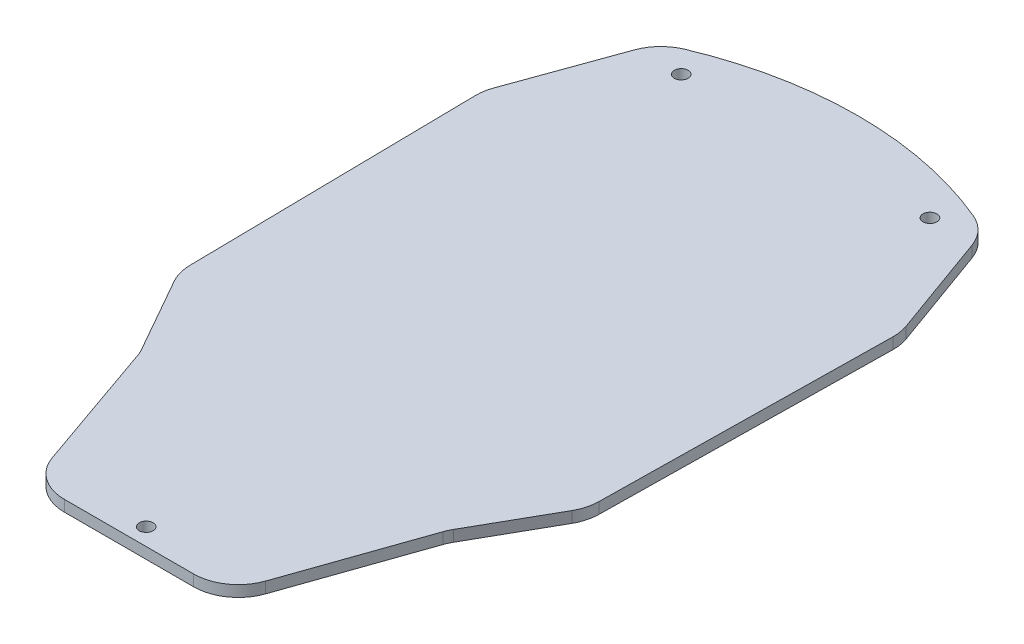
from build123d import *

# Parameters (mm, degrees)
BOSS_EXTRUDE1_DEPTH             = 3.175
F_5_32_0_15625_DIAMETER_HOLE1_D = 3.96875
FILLET1_R                       = 12.7


with BuildPart() as part:
    # Sketch1 → Boss-Extrude1 (new body)
    with BuildSketch(Plane(origin=(0, 0, 0), x_dir=(1, 0, 0), z_dir=(0, 1, 0))):
        with BuildLine():
            Line((-58.261140344, 73.958269638), (-59.57789635, 162.152192036))
            Line((-59.57789635, 162.152192036), (-46.350471986, 198.78134649))
            ThreePointArc((-46.350471986, 198.78134649), (0, 209.411849995), (46.350471986, 198.78134649))
            Line((46.350471986, 198.78134649), (59.57789635, 162.152192036))
            Line((59.57789635, 162.152192036), (58.261140344, 73.958269638))
            Line((58.261140344, 73.958269638), (43.887596105, 48.613026492))
            Line((43.887596105, 48.613026492), (27.448255842, 1.5875))
            Line((27.448255842, 1.5875), (-27.448255842, 1.5875))
            Line((-27.448255842, 1.5875), (-43.887596105, 48.613026492))
            Line((-43.887596105, 48.613026492), (-58.261140344, 73.958269638))
        make_face()
    extrude(amount=BOSS_EXTRUDE1_DEPTH)

    # 5/32 (0.15625) Diameter Hole1 (through all)
    with Locations(Plane(origin=(0, 3.175, 0), x_dir=(1, 0, 0), z_dir=(0, 1, 0))):
        with Locations((0, 6.48335), (-35.45205, 194.449583064), (35.45205, 194.449583064)):
            Hole(F_5_32_0_15625_DIAMETER_HOLE1_D / 2)

    # Fillet1
    fillet1_edges = [part.edges().sort_by_distance(p)[0] for p in [
        (-59.57789635, 1.5875, -162.152192036),
        (-58.261140344, 1.5875, -73.958269638),
        (-43.887596105, 1.5875, -48.613026492),
        (-27.448255842, 1.5875, -1.5875),
        (27.448255842, 1.5875, -1.5875),
        (43.887596105, 1.5875, -48.613026492),
        (58.261140344, 1.5875, -73.958269638),
        (59.57789635, 1.5875, -162.152192036),
        (46.350471986, 1.5875, -198.78134649),
        (-46.350471986, 1.5875, -198.78134649),
    ]]
    fillet(fillet1_edges, radius=FILLET1_R)


solid = part.part
